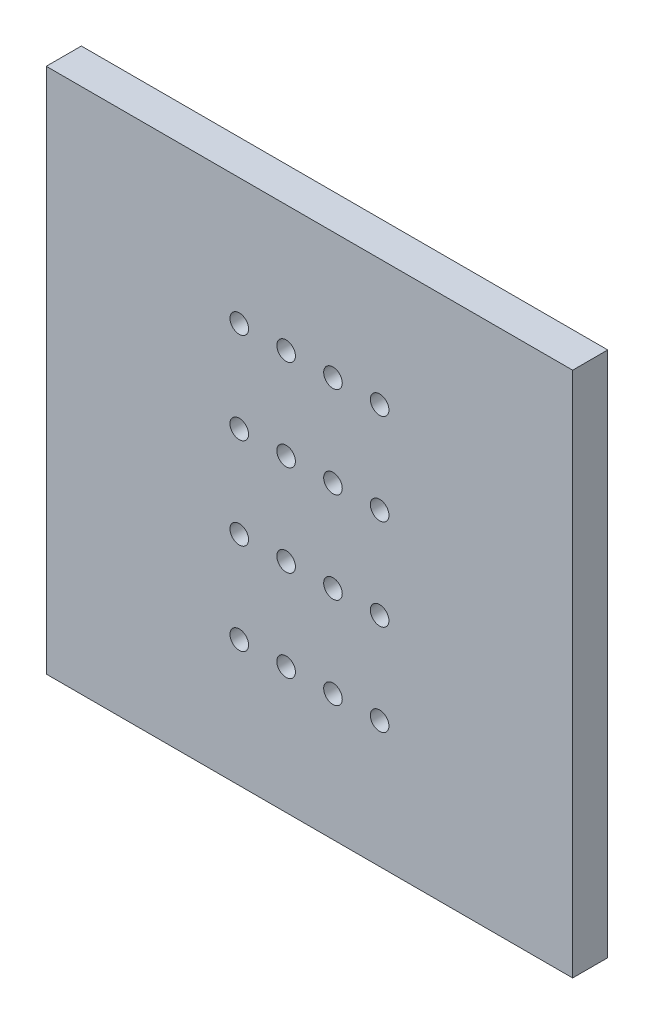
from build123d import *

# Parameters (mm, degrees)
ESQUISSE1_W            = 30
ESQUISSE1_H            = 30
BASE_PLATE_DEPTH       = 2
SKETCH_PERFORATIONS_R  = 0.53
CUT_PERFORATIONS_DEPTH = 10


with BuildPart() as part:
    # Esquisse1 → Base_Plate (new body)
    with BuildSketch(Plane.XY):
        Rectangle(ESQUISSE1_W, ESQUISSE1_H)
    extrude(amount=BASE_PLATE_DEPTH)

    # Sketch_Perforations → Cut_Perforations (cut)
    with BuildSketch(Plane.XY.offset(2)):
        with Locations((-4, -7.8)):
            Circle(SKETCH_PERFORATIONS_R)
        with Locations((-4, -2.6)):
            Circle(SKETCH_PERFORATIONS_R)
        with Locations((-4, 2.6)):
            Circle(SKETCH_PERFORATIONS_R)
        with Locations((-4, 7.8)):
            Circle(SKETCH_PERFORATIONS_R)
        with Locations((-1.33, -7.8)):
            Circle(SKETCH_PERFORATIONS_R)
        with Locations((-1.33, -2.6)):
            Circle(SKETCH_PERFORATIONS_R)
        with Locations((-1.33, 2.6)):
            Circle(SKETCH_PERFORATIONS_R)
        with Locations((-1.33, 7.8)):
            Circle(SKETCH_PERFORATIONS_R)
        with Locations((1.34, -7.8)):
            Circle(SKETCH_PERFORATIONS_R)
        with Locations((1.34, -2.6)):
            Circle(SKETCH_PERFORATIONS_R)
        with Locations((1.34, 2.6)):
            Circle(SKETCH_PERFORATIONS_R)
        with Locations((1.34, 7.8)):
            Circle(SKETCH_PERFORATIONS_R)
        with Locations((4, -7.8)):
            Circle(SKETCH_PERFORATIONS_R)
        with Locations((4, -2.6)):
            Circle(SKETCH_PERFORATIONS_R)
        with Locations((4, 2.6)):
            Circle(SKETCH_PERFORATIONS_R)
        with Locations((4, 7.8)):
            Circle(SKETCH_PERFORATIONS_R)
    extrude(amount=-CUT_PERFORATIONS_DEPTH, mode=Mode.SUBTRACT)


solid = part.part
